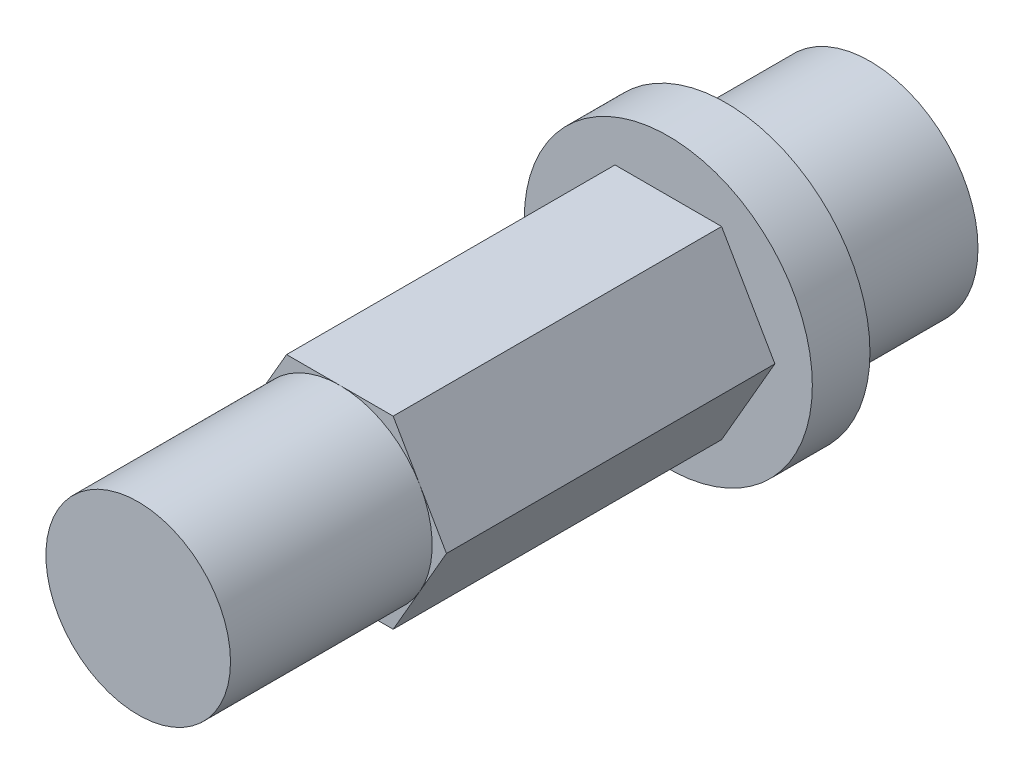
from build123d import *

# Parameters (mm, degrees)
SKETCH1_R           = 3.75
BOSS_EXTRUDE1_DEPTH = 5
SKETCH2_R           = 5
BOSS_EXTRUDE2_DEPTH = 2
BOSS_EXTRUDE3_DEPTH = 11.4
SKETCH4_R           = 3.204293994
BOSS_EXTRUDE4_DEPTH = 7


with BuildPart() as part:
    # Sketch1 → Boss-Extrude1 (new body)
    with BuildSketch(Plane.XY):
        Circle(SKETCH1_R)
    extrude(amount=BOSS_EXTRUDE1_DEPTH)

    # Sketch2 → Boss-Extrude2 (add)
    with BuildSketch(Plane.XY.offset(5)):
        Circle(SKETCH2_R)
    extrude(amount=BOSS_EXTRUDE2_DEPTH)

    # Sketch3 → Boss-Extrude3 (add)
    with BuildSketch(Plane.XY.offset(7)):
        Polygon((3.7, 0), (1.85, 3.204293994), (-1.85, 3.204293994), (-3.7, 0), (-1.85, -3.204293994), (1.85, -3.204293994), align=None)
    extrude(amount=BOSS_EXTRUDE3_DEPTH)

    # Sketch4 → Boss-Extrude4 (add)
    with BuildSketch(Plane.XY.offset(18.4)):
        Circle(SKETCH4_R)
    extrude(amount=BOSS_EXTRUDE4_DEPTH)


solid = part.part
